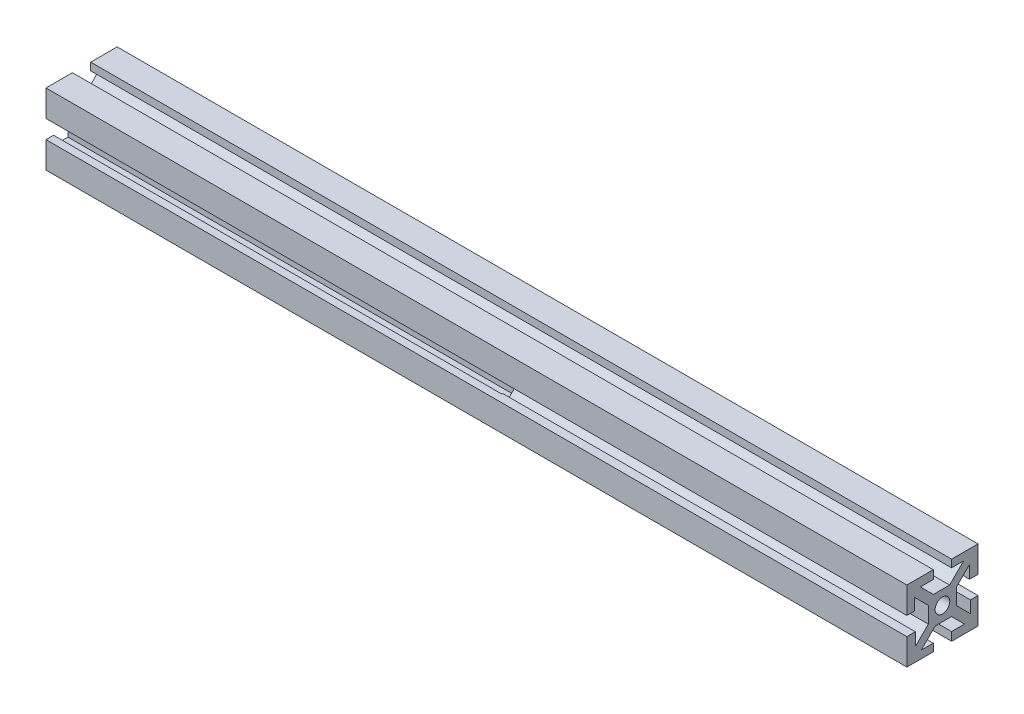
from build123d import *

# Parameters (mm, degrees)
SKETCH1_R           = 2.605
BOSS_EXTRUDE1_DEPTH = 304.8
CIRPATTERN1_COUNT   = 4
SKETCH2_R           = 2.78
CUT_EXTRUDE1_DEPTH  = 30
SKETCH3_W           = 5.08
SKETCH3_H           = 12.7
CUT_EXTRUDE2_DEPTH  = 158.75


with BuildPart() as part:
    # Sketch1 → Boss-Extrude1 (new body)
    with BuildSketch(Plane(origin=(0, 0, 0), x_dir=(0, 0, -1), z_dir=(1, 0, 0))):
        Polygon((5, -5), (5, 3.203948776), (9.596194078, 7.800142853), (9.596194078, 3.24), (12.596194078, 3.24), (12.596194078, 12.596194078), (3.24, 12.596194078), (3.24, 9.921463197), (7.474873734, 9.921463197), (2.553410537, 5), (-5, 5), (-5, -5), align=None)
        Circle(SKETCH1_R, mode=Mode.SUBTRACT)
    boss_extrude1 = extrude(amount=BOSS_EXTRUDE1_DEPTH)

    # CirPattern1: Boss-Extrude1 ×4 about axis
    cirpattern1_axis = Axis((0, 0, 0), (1, 0, 0))
    for i in range(1, CIRPATTERN1_COUNT):
        add(boss_extrude1.rotate(cirpattern1_axis, i * 360 / CIRPATTERN1_COUNT))

    # Sketch2 → Cut-Extrude1 (cut)
    with BuildSketch(Plane.XY.offset(12.596194078)):
        with Locations((152.4, 0)):
            Circle(SKETCH2_R)
    extrude(amount=-CUT_EXTRUDE1_DEPTH, mode=Mode.SUBTRACT)

    # Sketch3 → Cut-Extrude2 (cut)
    with BuildSketch(Plane.ZY):
        with Locations((7.381463197, 0)):
            Rectangle(SKETCH3_W, SKETCH3_H)
    extrude(amount=-CUT_EXTRUDE2_DEPTH, mode=Mode.SUBTRACT)


solid = part.part
